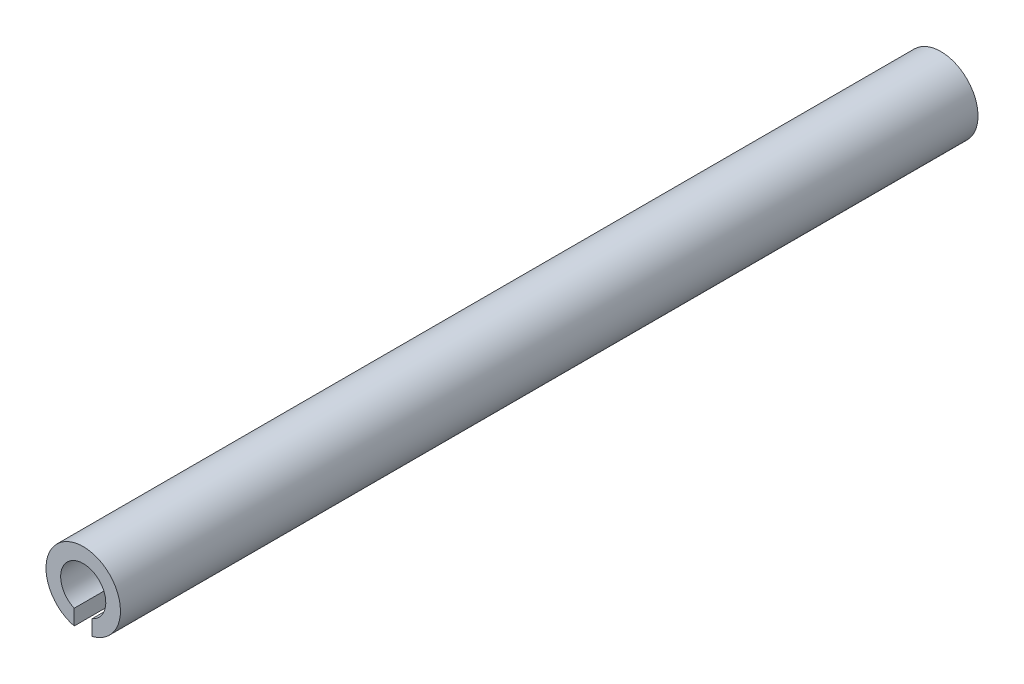
from build123d import *

# Parameters (mm, degrees)
DOWEL_BODY_DEPTH = 38


with BuildPart() as part:
    # Sketch1 → dowel_body (new body)
    with BuildSketch(Plane.XY):
        with BuildLine():
            Line((-0.4, -1.600781059), (-0.4, -0.916515139))
            ThreePointArc((-0.4, -0.916515139), (-0.547722558, 0.836660027), (1, 0))
            ThreePointArc((1, 0), (0.836660027, -0.547722558), (0.4, -0.916515139))
            Line((0.4, -0.916515139), (0.4, -1.600781059))
            ThreePointArc((0.4, -1.600781059), (1.30048068, -1.015504801), (1.65, 0))
            ThreePointArc((1.65, 0), (-1.015504801, 1.30048068), (-0.4, -1.600781059))
        make_face()
    extrude(amount=DOWEL_BODY_DEPTH)


solid = part.part
